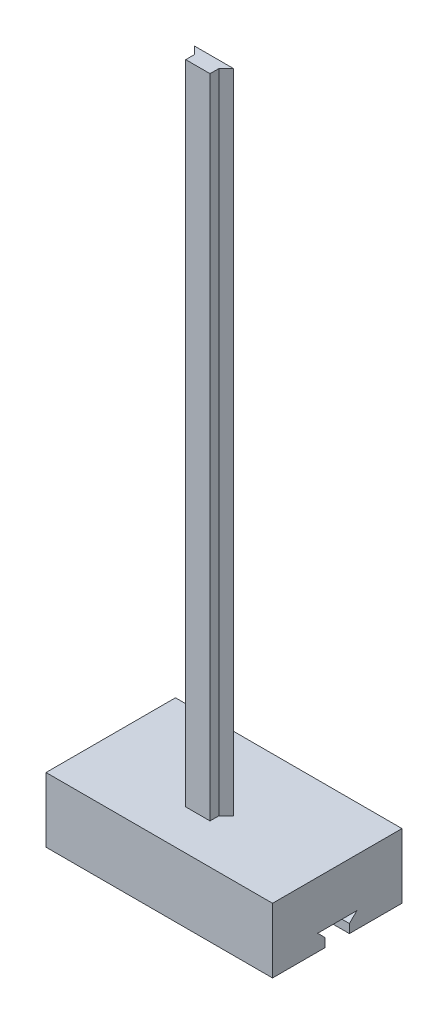
from build123d import *

# Parameters (mm, degrees)
SKETCH1_W           = 177.8
SKETCH1_H           = 101.6
BOSS_EXTRUDE1_DEPTH = 50.8
CUT_EXTRUDE1_DEPTH  = 178.8
BOSS_EXTRUDE2_DEPTH = 508


with BuildPart() as part:
    # Sketch1 → Boss-Extrude1 (new body)
    with BuildSketch(Plane(origin=(0, 0, 0), x_dir=(1, 0, 0), z_dir=(0, 1, 0))):
        with Locations((88.9, 50.8)):
            Rectangle(SKETCH1_W, SKETCH1_H)
    extrude(amount=BOSS_EXTRUDE1_DEPTH)

    # Sketch2 → Cut-Extrude1 (cut, through all)
    with BuildSketch(Plane(origin=(177.8, 0, 0), x_dir=(0, 0, -1), z_dir=(1, 0, 0))):
        Polygon((41.275, 0), (41.275, 6.858), (35.433, 12.7), (66.167, 12.7), (60.325, 6.858), (60.325, 0), align=None)
    extrude(amount=-CUT_EXTRUDE1_DEPTH, mode=Mode.SUBTRACT)

    # Sketch3 → Boss-Extrude2 (add)
    with BuildSketch(Plane(origin=(0, 50.8, 0), x_dir=(1, 0, 0), z_dir=(0, 1, 0))):
        Polygon((78.242626062, 31.429656714), (78.242626062, 38.287656714), (72.400626062, 44.129656714), (103.134626062, 44.129656714), (97.292626062, 38.287656714), (97.292626062, 31.429656714), align=None)
    extrude(amount=BOSS_EXTRUDE2_DEPTH)


solid = part.part
